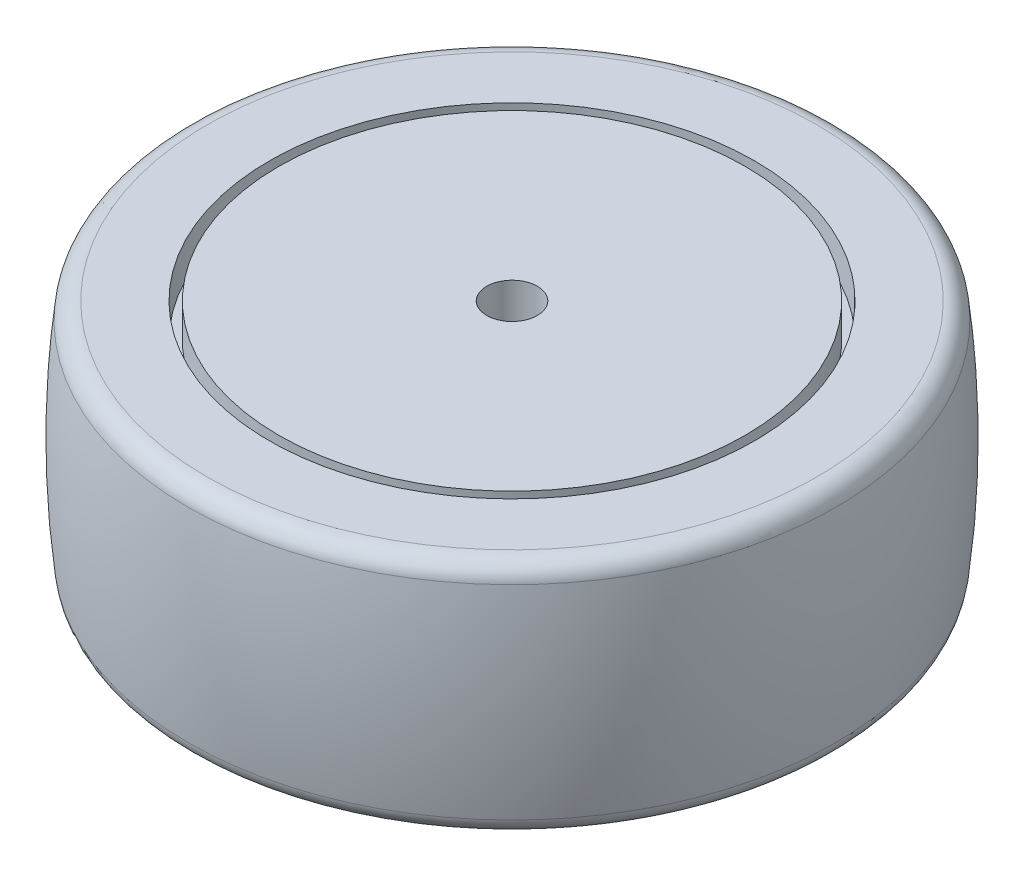
from build123d import *

# Parameters (mm, degrees)
FILLET1_R          = 3
SKETCH2_R          = 4
CUT_EXTRUDE1_DEPTH = 137


with BuildPart() as part:
    # Sketch1 → Revolve2 (revolve)
    with BuildSketch(Plane.XY, mode=Mode.PRIVATE) as revolve2_sk:
        with BuildLine():
            Line((-50.8, 18.75), (-38.3, 18.75))
            Line((-38.3, 18.75), (-38.3, 13.2825304))
            Line((-38.3, 13.2825304), (-36.8, 13.2825304))
            Line((-36.8, 13.2825304), (-36.8, 18.75))
            Line((-36.8, 18.75), (0, 18.75))
            Line((0, 18.75), (0, -18.75))
            Line((0, -18.75), (-36.8, -18.75))
            Line((-36.8, -18.75), (-36.8, -13.2825304))
            Line((-36.8, -13.2825304), (-38.3, -13.2825304))
            Line((-38.3, -13.2825304), (-38.3, -18.75))
            Line((-38.3, -18.75), (-50.8, -18.75))
            ThreePointArc((-50.8, -18.75), (-52.039597726, 0), (-50.8, 18.75))
        make_face()
    revolve(revolve2_sk.sketch.rotate(Axis((0, -18.75, 0), (0, 1, 0)), 270), axis=Axis((0, -18.75, 0), (0, 1, 0)))  # turned: the seam where the file's is

    # Fillet1
    fillet1_edges = [part.edges().sort_by_distance(p)[0] for p in [
        (0, -18.75, 50.8),
        (0, 18.75, 50.8),
    ]]
    fillet(fillet1_edges, radius=FILLET1_R)

    # Sketch2 → Cut-Extrude1 (cut)
    with BuildSketch(Plane(origin=(0, 18.75, 0), x_dir=(1, 0, 0), z_dir=(0, 1, 0))):
        with Locations(Location((0, 0, 0), (0, 0, 270))):  # turned: the seam where the file's is
            Circle(SKETCH2_R)
    extrude(amount=-CUT_EXTRUDE1_DEPTH, mode=Mode.SUBTRACT)


solid = part.part
